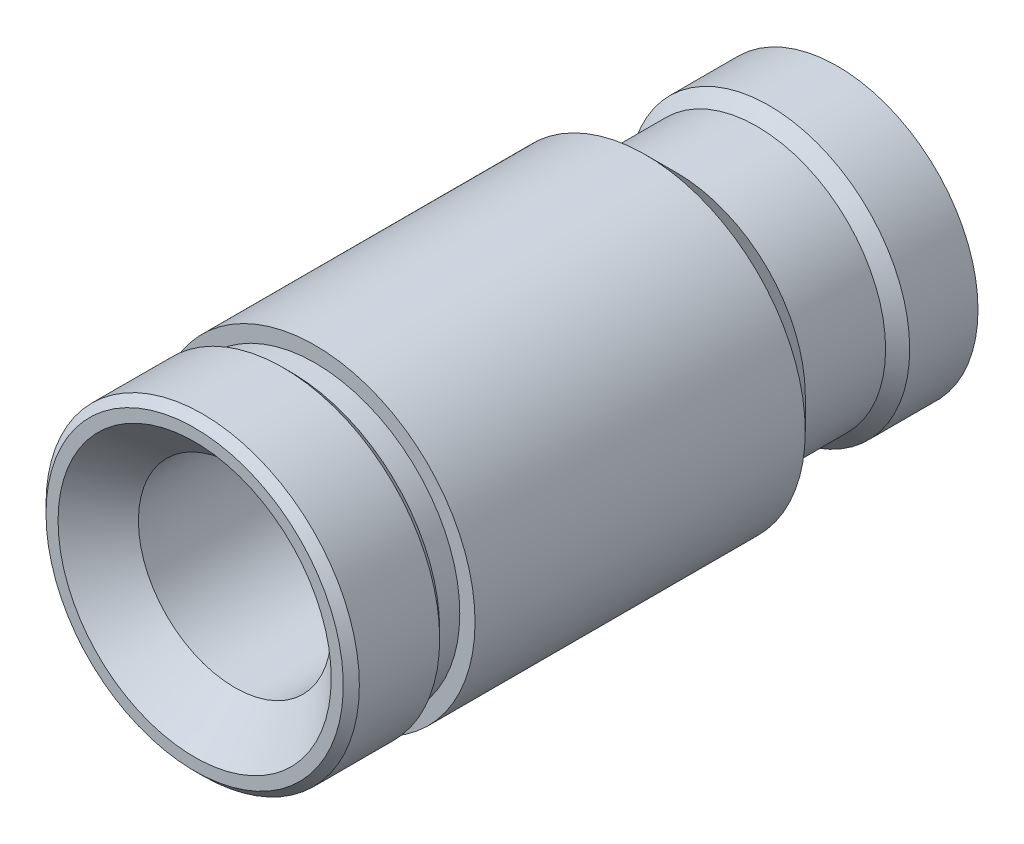
from build123d import *

# Parameters (mm, degrees)
CHANFRO1_SIZE = 1
CHANFRO3_SIZE = 2
CHANFRO4_SIZE = 5


with BuildPart() as part:
    # Esboço1 → Revolução1 (revolve)
    with BuildSketch(Plane(origin=(0, 0, 0), x_dir=(0, 0, -1), z_dir=(1, 0, 0))):
        Polygon((0.5, 12), (0.5, 19.5), (12.5, 19.5), (12.5, 18), (15.5, 18), (15.5, 19.9), (56.6, 19.9), (60.5, 16), (70.5, 16), (72, 17.5), (80.5, 17.5), (80.5, 12), (80.5, 11), (63.5, 11), (63.5, 12), align=None)
    revolve(axis=Axis((0, 0, 0), (0, 0, -1)))

    # Chanfro1
    chanfro1_edges = [part.edges().sort_by_distance(p)[0] for p in [
        (0, -19.5, -0.5),
        (0, -19.5, -12.5),
    ]]
    chamfer(chanfro1_edges, length=CHANFRO1_SIZE)

    # Chanfro3
    chanfro3_edges = [part.edges().sort_by_distance(p)[0] for p in [
        (0, -11, -80.5),
    ]]
    chamfer(chanfro3_edges, length=CHANFRO3_SIZE)

    # Chanfro4
    chanfro4_edges = [part.edges().sort_by_distance(p)[0] for p in [
        (0, -12, -0.5),
    ]]
    chamfer(chanfro4_edges, length=CHANFRO4_SIZE)


solid = part.part
